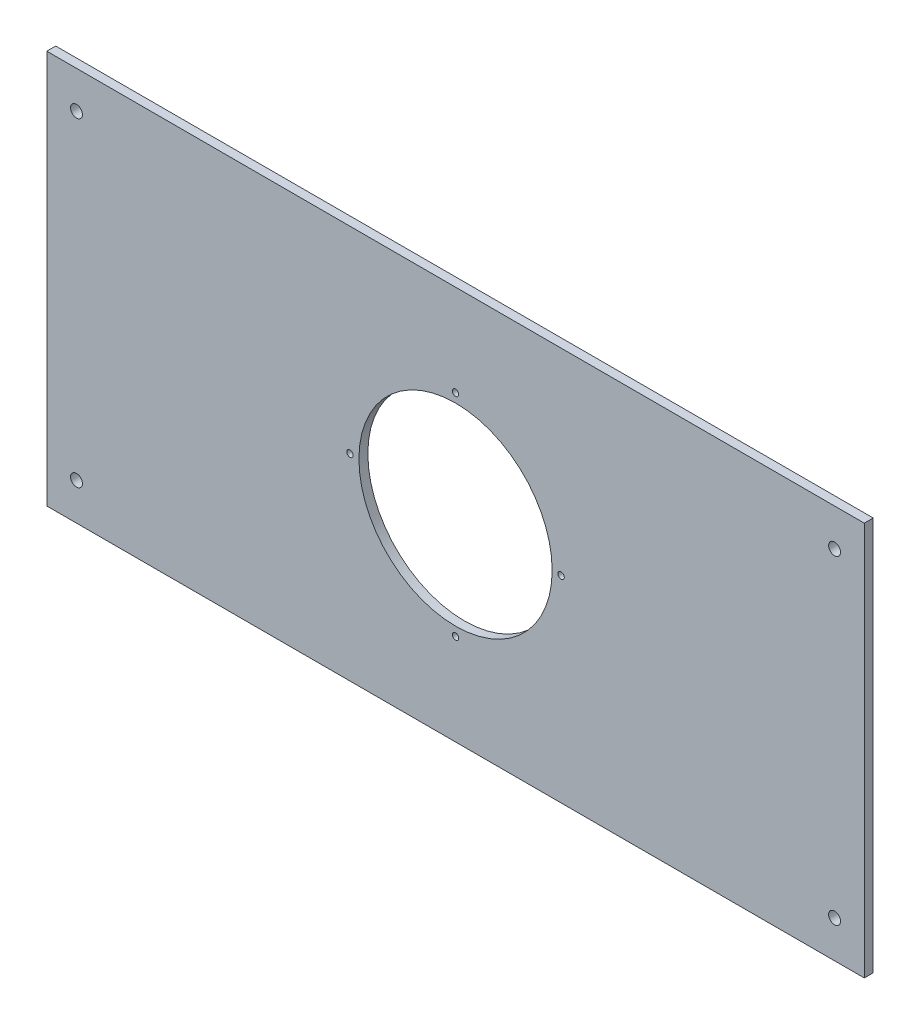
from build123d import *

# Parameters (mm, degrees)
ESQUISSE1_W             = 550
ESQUISSE1_H             = 265
BOSS_EXTRU_1_DEPTH      = 6
ESQUISSE2_R             = 65
ESQUISSE2_R_2           = 2.15
ESQUISSE2_R_3           = 4
ENL_V_MAT_EXTRU_1_DEPTH = 6


with BuildPart() as part:
    # Esquisse1 → Boss.-Extru.1 (new body)
    with BuildSketch(Plane.XY):
        with Locations((94.366197183, 26.029929577)):
            Rectangle(ESQUISSE1_W, ESQUISSE1_H)
    extrude(amount=BOSS_EXTRU_1_DEPTH)

    # Esquisse2 → Enlèv. mat.-Extru.1 (cut)
    with BuildSketch(Plane.XY.offset(6)):
        with Locations((94.366197183, 26.029929577)):
            Circle(ESQUISSE2_R)
        with Locations((94.366197183, 97.029929577)):
            Circle(ESQUISSE2_R_2)
        with Locations((165.366197183, 26.029929577)):
            Circle(ESQUISSE2_R_2)
        with Locations((94.366197183, -44.970070423)):
            Circle(ESQUISSE2_R_2)
        with Locations((23.366197183, 26.029929577)):
            Circle(ESQUISSE2_R_2)
        with Locations((-160.633802817, 133.529929577)):
            Circle(ESQUISSE2_R_3)
        with Locations((349.366197183, 133.529929577)):
            Circle(ESQUISSE2_R_3)
        with Locations((349.366197183, -81.470070423)):
            Circle(ESQUISSE2_R_3)
        with Locations((-160.633802817, -81.470070423)):
            Circle(ESQUISSE2_R_3)
    extrude(amount=-ENL_V_MAT_EXTRU_1_DEPTH, mode=Mode.SUBTRACT)


solid = part.part
